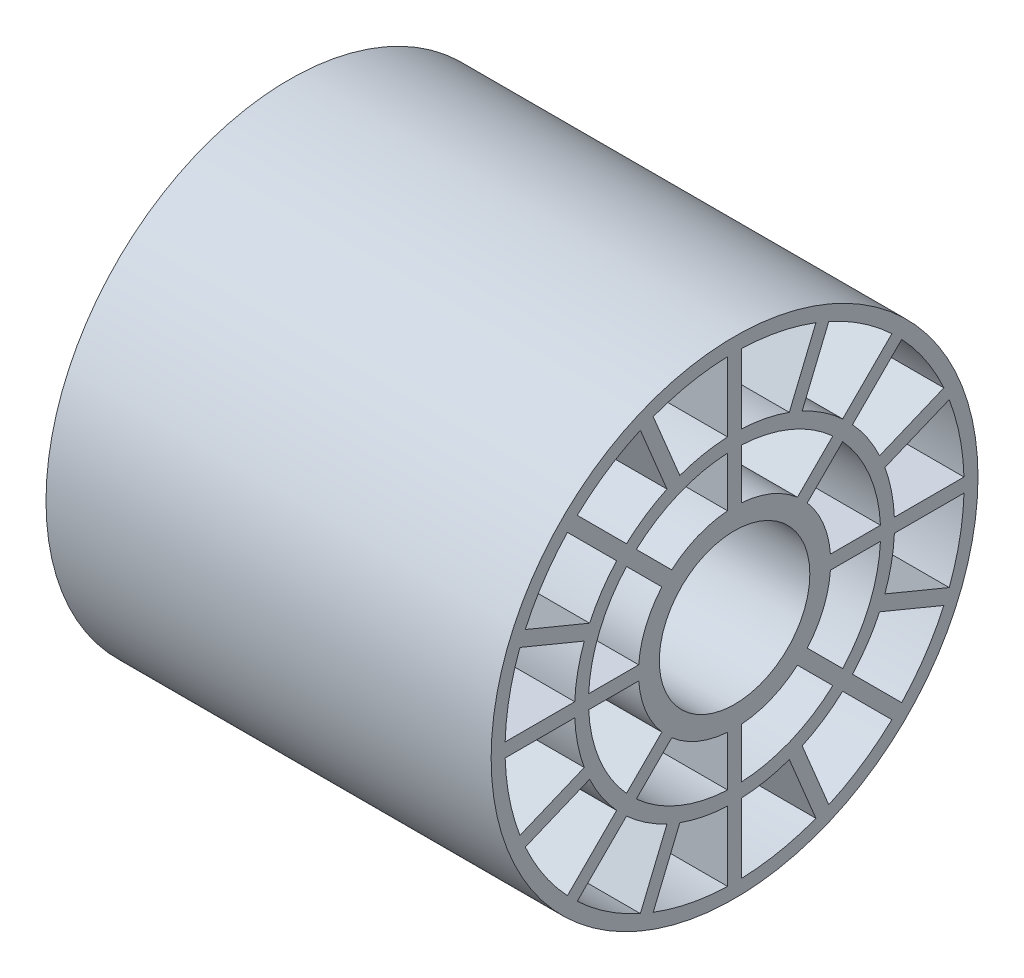
from build123d import *

# Parameters (mm, degrees)
SKETCH1_R             = 22.225
SKETCH1_R_2           = 20.955
EXTRUDE_THIN1_DEPTH   = 20.32
SKETCH1_R_3           = 14.605
SKETCH1_R_4           = 13.335
EXTRUDE_THIN1_2_DEPTH = 20.32
SKETCH1_3_R           = 8.7757
SKETCH1_3_R_2         = 6.8707
EXTRUDE_THIN2_DEPTH   = 20.32
SKETCH2_W             = 1.27
SKETCH2_H             = 41.91
SKETCH2_W_2           = 41.91
SKETCH2_H_2           = 1.27
EXTRUDE_THIN3_DEPTH   = 20.32
SKETCH1_5_R           = 6.8707
CUT_EXTRUDE1_DEPTH    = 20.32
EXTRUDE_THIN6_DEPTH   = 20.32
CIRPATTERN1_COUNT     = 8


with BuildPart() as part:
    # Sketch1 → Extrude-Thin1 (new body, symmetric)
    with BuildSketch(Plane(origin=(0, 0, 0), x_dir=(0, 0, -1), z_dir=(1, 0, 0))):
        Circle(SKETCH1_R)
        Circle(SKETCH1_R_2, mode=Mode.SUBTRACT)
    extrude(amount=EXTRUDE_THIN1_DEPTH, both=True)



with BuildPart() as body_2:
    # Sketch1 → Extrude-Thin1 2 (new body, symmetric)
    with BuildSketch(Plane(origin=(0, 0, 0), x_dir=(0, 0, -1), z_dir=(1, 0, 0))):
        Circle(SKETCH1_R_3)
        Circle(SKETCH1_R_4, mode=Mode.SUBTRACT)
    extrude(amount=EXTRUDE_THIN1_2_DEPTH, both=True)


with BuildPart() as body_3:
    # Sketch1_3 → Extrude-Thin2 (new body, symmetric)
    with BuildSketch(Plane(origin=(0, 0, 0), x_dir=(0, 0, -1), z_dir=(1, 0, 0))):
        Circle(SKETCH1_3_R)
        Circle(SKETCH1_3_R_2, mode=Mode.SUBTRACT)
    extrude(amount=EXTRUDE_THIN2_DEPTH, both=True)


with BuildPart() as part_1:
    add(part.part)

    add(body_3.part)  # Extrude-Thin3 merges body 3
    # Sketch2 → Extrude-Thin3 (add, symmetric)
    with BuildSketch(Plane(origin=(0, 0, 0), x_dir=(0, 0, -1), z_dir=(1, 0, 0))):
        Rectangle(SKETCH2_W, SKETCH2_H)
        Rectangle(SKETCH2_W_2, SKETCH2_H_2)
        Polygon((-14.368409794, -15.266435406), (15.266435406, 14.368409794), (14.368409794, 15.266435406), (-15.266435406, -14.368409794), align=None)
        Polygon((-15.266435406, 14.368409794), (14.368409794, -15.266435406), (15.266435406, -14.368409794), (-14.368409794, 15.266435406), align=None)
    extrude(amount=EXTRUDE_THIN3_DEPTH, both=True)

    # Sketch1_5 → Cut-Extrude1 (cut, symmetric)
    with BuildSketch(Plane(origin=(0, 0, 0), x_dir=(0, 0, -1), z_dir=(1, 0, 0))):
        Circle(SKETCH1_5_R)
    extrude(amount=CUT_EXTRUDE1_DEPTH, both=True, mode=Mode.SUBTRACT)


    add(body_2.part)  # Extrude-Thin6 merges body 2
    # Sketch4 → Extrude-Thin6 (add, symmetric)
    with BuildSketch(Plane(origin=(0, 0, 0), x_dir=(0, 0, -1), z_dir=(1, 0, 0))):
        Polygon((-8.605794828, 19.116891624), (-5.981351849, 12.78092579), (-4.808024843, 13.266933749), (-7.432467822, 19.602899583), align=None)
    extrude_thin6 = extrude(amount=EXTRUDE_THIN6_DEPTH, both=True)

    # CirPattern1: Extrude-Thin6 ×8 about axis
    cirpattern1_axis = Axis((0, 0, 0), (1, 0, 0))
    for i in range(1, CIRPATTERN1_COUNT):
        add(extrude_thin6.rotate(cirpattern1_axis, i * 360 / CIRPATTERN1_COUNT))


solid = part_1.part
